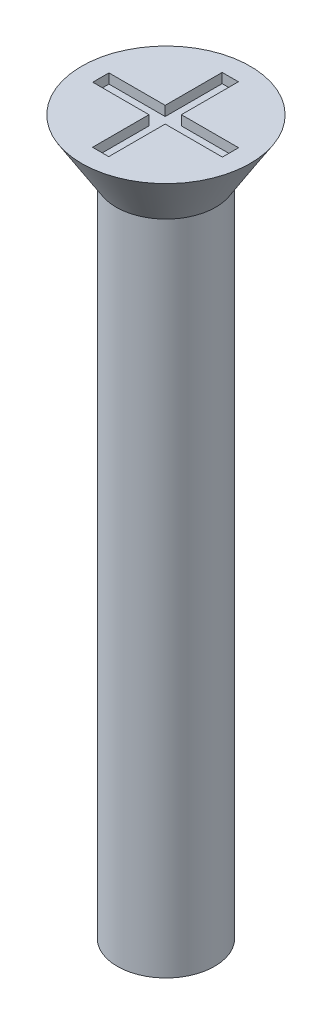
from build123d import *

# Parameters (mm, degrees)
SKETCH1_R           = 1.5
BOSS_EXTRUDE1_DEPTH = 22
SKETCH2_R           = 2.6
BOSS_EXTRUDE2_DEPTH = 1.7
BOSS_EXTRUDE2_TAPER = 32
SKETCH3_W           = 0.5
SKETCH3_H           = 1.758378485
SKETCH3_H_2         = 1.741621515
SKETCH3_W_2         = 1.734727157
SKETCH3_H_3         = 0.5
SKETCH3_W_3         = 1.765272843
CUT_EXTRUDE1_DEPTH  = 0.3


with BuildPart() as part:
    # Sketch1 → Boss-Extrude1 (new body)
    with BuildSketch(Plane(origin=(0, 0, 0), x_dir=(1, 0, 0), z_dir=(0, 1, 0))):
        Circle(SKETCH1_R)
    extrude(amount=BOSS_EXTRUDE1_DEPTH)

    # Sketch2 → Boss-Extrude2 (add)
    with BuildSketch(Plane(origin=(0, 22, 0), x_dir=(1, 0, 0), z_dir=(0, 1, 0))):
        Circle(SKETCH2_R)
    extrude(amount=-BOSS_EXTRUDE2_DEPTH, taper=BOSS_EXTRUDE2_TAPER)

    # Sketch3 → Cut-Extrude1 (cut)
    with BuildSketch(Plane(origin=(0, 22, 0), x_dir=(1, 0, 0), z_dir=(0, 1, 0))):
        with Locations((-0.015272843, 1.120810757)):
            Rectangle(SKETCH3_W, SKETCH3_H)
        with Locations((-0.015272843, -1.129189243)):
            Rectangle(SKETCH3_W, SKETCH3_H_2)
        with Locations((-1.132636421, -0.008378485)):
            Rectangle(SKETCH3_W_2, SKETCH3_H_3)
        with Locations((1.117363579, -0.008378485)):
            Rectangle(SKETCH3_W_3, SKETCH3_H_3)
        with Locations((-0.015272843, -0.008378485)):
            Rectangle(SKETCH3_W, SKETCH3_H_3)
    extrude(amount=-CUT_EXTRUDE1_DEPTH, mode=Mode.SUBTRACT)


solid = part.part
